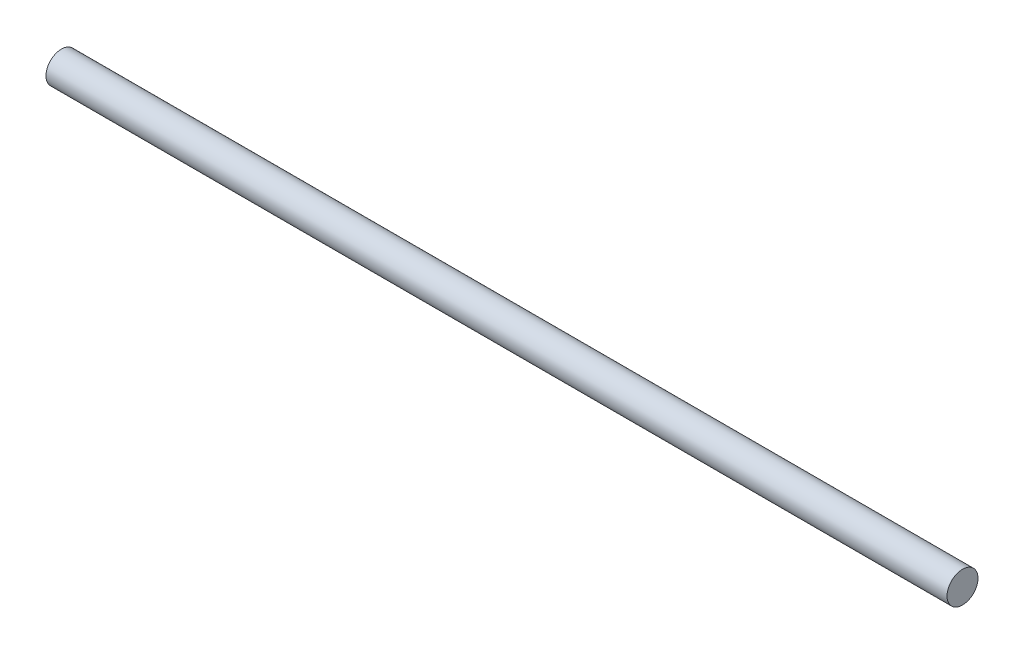
from build123d import *

# Parameters (mm, degrees)
SKETCH1_R           = 15
BOSS_EXTRUDE1_DEPTH = 873


with BuildPart() as part:
    # Sketch1 → Boss-Extrude1 (new body)
    with BuildSketch(Plane(origin=(0, 0, 0), x_dir=(0, 0, -1), z_dir=(1, 0, 0))):
        Circle(SKETCH1_R)
    extrude(amount=BOSS_EXTRUDE1_DEPTH)


solid = part.part
